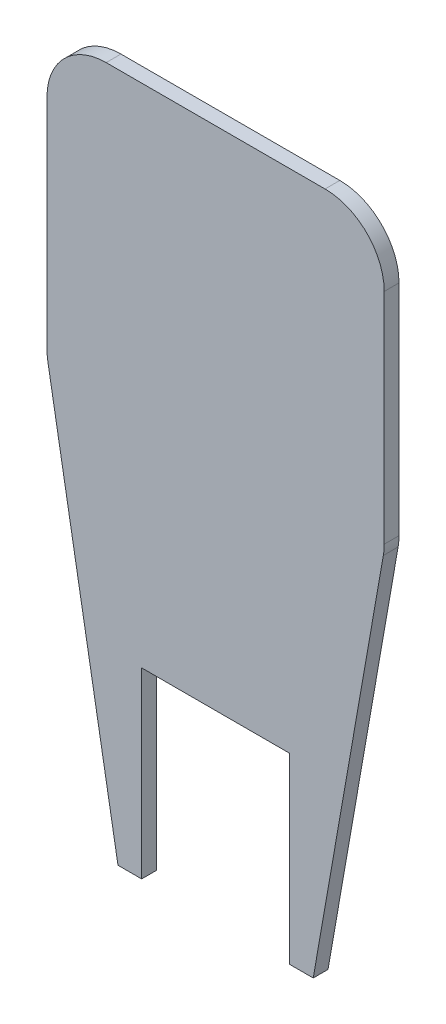
from build123d import *

# Parameters (mm, degrees)
SALIENTE_EXTRUIR1_DEPTH = 2.5


with BuildPart() as part:
    # Croquis1 → Saliente-Extruir1 (new body)
    with BuildSketch(Plane.XY):
        with BuildLine():
            Line((-16.5, -88), (-12.5, -88))
            Line((-12.5, -88), (-12.5, -57.1))
            Line((-12.5, -57.1), (12.5, -57.1))
            Line((12.5, -57.1), (12.5, -88))
            Line((12.5, -88), (16.5, -88))
            Line((16.5, -88), (28.350564417, -20.2223184))
            ThreePointArc((28.350564417, -20.2223184), (28.462571058, -19.364394538), (28.5, -18.5))
            Line((28.5, -18.5), (28.5, 18.5))
            ThreePointArc((28.5, 18.5), (25.571067812, 25.571067812), (18.5, 28.5))
            Line((18.5, 28.5), (-18.5, 28.5))
            ThreePointArc((-18.5, 28.5), (-25.571067812, 25.571067812), (-28.5, 18.5))
            Line((-28.5, 18.5), (-28.5, -18.5))
            ThreePointArc((-28.5, -18.5), (-28.462571058, -19.364394538), (-28.350564417, -20.2223184))
            Line((-28.350564417, -20.2223184), (-16.5, -88))
        make_face()
    extrude(amount=SALIENTE_EXTRUIR1_DEPTH)


solid = part.part
